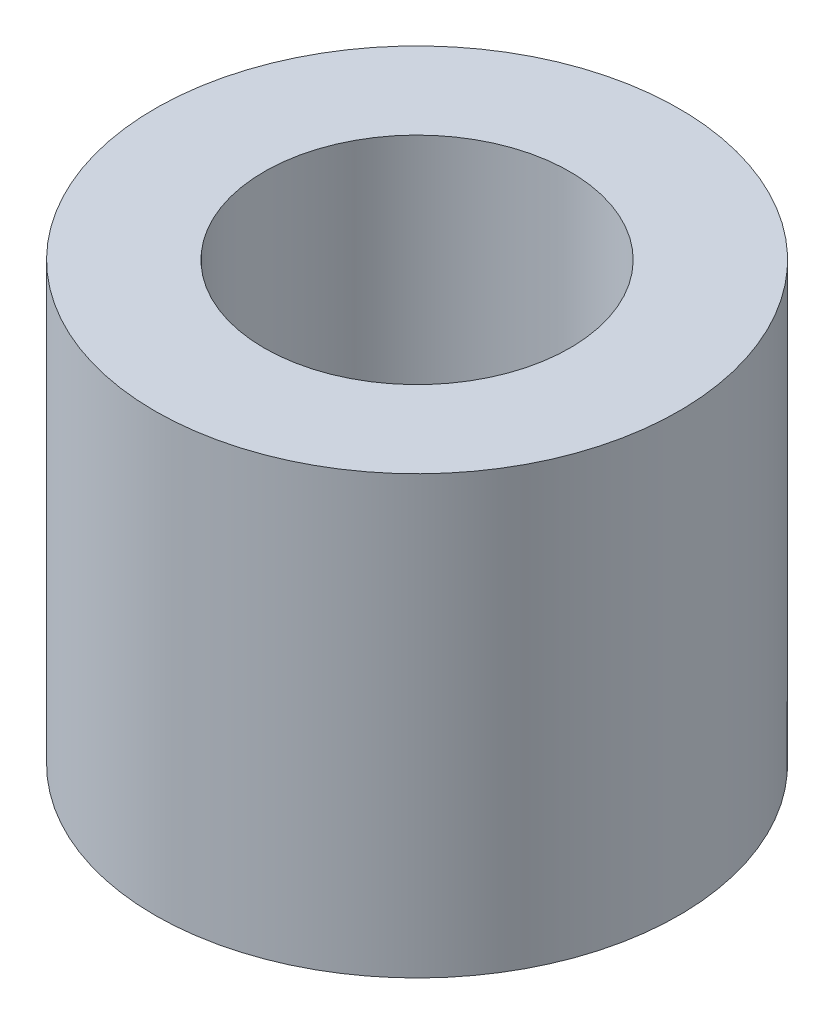
from build123d import *

# Parameters (mm, degrees)
SKETCH_1_R      = 3
SKETCH_1_R_2    = 1.75
EXTRUDE_1_DEPTH = 5


with BuildPart() as part:
    # ｽｹｯﾁ1 → ﾎﾞｽ - 押し出し1 (new body)
    with BuildSketch(Plane(origin=(0, 0, 0), x_dir=(1, 0, 0), z_dir=(0, 1, 0))):
        Circle(SKETCH_1_R)
        Circle(SKETCH_1_R_2, mode=Mode.SUBTRACT)
    extrude(amount=EXTRUDE_1_DEPTH)


solid = part.part
